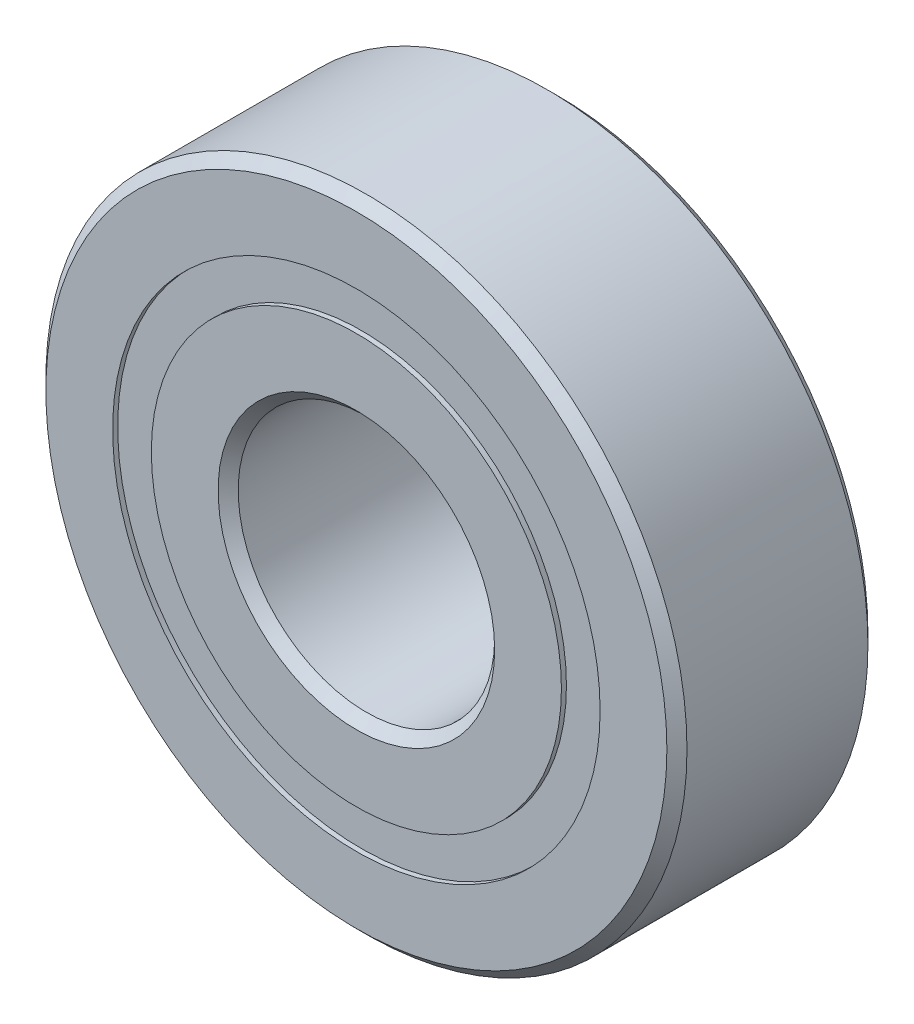
from build123d import *

# Parameters (mm, degrees)
CIRPATTERN1_COUNT = 8
SKETCH5_W         = 1.15919535
SKETCH5_H         = 0.957942858


with BuildPart() as part:
    # Sketch1 → Revolve1 (revolve)
    with BuildSketch(Plane(origin=(0, 0, 0), x_dir=(0, 0, -1), z_dir=(1, 0, 0))):
        with BuildLine():
            Line((2.24028, 7.9375), (-2.24028, 7.9375))
            Line((-2.24028, 7.9375), (-2.4892, 7.68858))
            Line((-2.4892, 7.68858), (-2.4892, 6.035221429))
            Line((-2.4892, 6.035221429), (-1.106311111, 6.035221429))
            ThreePointArc((-1.106311111, 6.035221429), (0, 6.76179465), (1.106311111, 6.035221429))
            Line((1.106311111, 6.035221429), (2.4892, 6.035221429))
            Line((2.4892, 6.035221429), (2.4892, 7.68858))
            Line((2.4892, 7.68858), (2.24028, 7.9375))
        make_face()
    revolve(axis=Axis((0, 0, 2.4892), (0, 0, -1)))


with BuildPart() as body_2:
    # Sketch3 → Revolve3 (revolve)
    with BuildSketch(Plane(origin=(0, 0, 0), x_dir=(0, 0, -1), z_dir=(1, 0, 0))):
        with BuildLine():
            Line((-2.4892, 5.077278571), (-1.106311111, 5.077278571))
            ThreePointArc((-1.106311111, 5.077278571), (0, 4.35070535), (1.106311111, 5.077278571))
            Line((1.106311111, 5.077278571), (2.4892, 5.077278571))
            Line((2.4892, 5.077278571), (2.4892, 3.42392))
            Line((2.4892, 3.42392), (2.24028, 3.175))
            Line((2.24028, 3.175), (-2.24028, 3.175))
            Line((-2.24028, 3.175), (-2.4892, 3.42392))
            Line((-2.4892, 3.42392), (-2.4892, 5.077278571))
        make_face()
    revolve(axis=Axis((0, 0, 2.4892), (0, 0, -1)))


with BuildPart() as body_3:
    # Sketch4 → Revolve4 (revolve)
    with BuildSketch(Plane(origin=(0, 0, 0), x_dir=(0, 0, -1), z_dir=(1, 0, 0))):
        with BuildLine():
            Line((-1.20554465, 5.55625), (1.20554465, 5.55625))
            ThreePointArc((1.20554465, 5.55625), (0, 6.76179465), (-1.20554465, 5.55625))
        make_face()
    revolve(axis=Axis((0, 5.55625, 1.20554465), (0, 0, -1)))


with BuildPart() as cirpattern1_1:
    # CirPattern1: pattern copy
    add(body_3.part.rotate(Axis((0, 0, 0), (0, 0, 1)), 1 * 360 / CIRPATTERN1_COUNT))


with BuildPart() as cirpattern1_2:
    # CirPattern1: pattern copy
    add(body_3.part.rotate(Axis((0, 0, 0), (0, 0, 1)), 2 * 360 / CIRPATTERN1_COUNT))


with BuildPart() as cirpattern1_3:
    # CirPattern1: pattern copy
    add(body_3.part.rotate(Axis((0, 0, 0), (0, 0, 1)), 3 * 360 / CIRPATTERN1_COUNT))


with BuildPart() as cirpattern1_4:
    # CirPattern1: pattern copy
    add(body_3.part.rotate(Axis((0, 0, 0), (0, 0, 1)), 4 * 360 / CIRPATTERN1_COUNT))


with BuildPart() as cirpattern1_5:
    # CirPattern1: pattern copy
    add(body_3.part.rotate(Axis((0, 0, 0), (0, 0, 1)), 5 * 360 / CIRPATTERN1_COUNT))


with BuildPart() as cirpattern1_6:
    # CirPattern1: pattern copy
    add(body_3.part.rotate(Axis((0, 0, 0), (0, 0, 1)), 6 * 360 / CIRPATTERN1_COUNT))


with BuildPart() as cirpattern1_7:
    # CirPattern1: pattern copy
    add(body_3.part.rotate(Axis((0, 0, 0), (0, 0, 1)), 7 * 360 / CIRPATTERN1_COUNT))


with BuildPart() as body_11:
    # Sketch5 → Revolve5 (revolve)
    with BuildSketch(Plane(origin=(0, 0, 0), x_dir=(0, 0, -1), z_dir=(1, 0, 0))):
        with Locations((-1.785142325, 5.55625)):
            Rectangle(SKETCH5_W, SKETCH5_H)
        with Locations((1.785142325, 5.55625)):
            Rectangle(SKETCH5_W, SKETCH5_H)
    revolve(axis=Axis((0, 0, 2.4892), (0, 0, -1)))


solid = Compound([part.part, body_2.part, body_3.part, cirpattern1_1.part, cirpattern1_2.part, cirpattern1_3.part, cirpattern1_4.part, cirpattern1_5.part, cirpattern1_6.part, cirpattern1_7.part, body_11.part])
